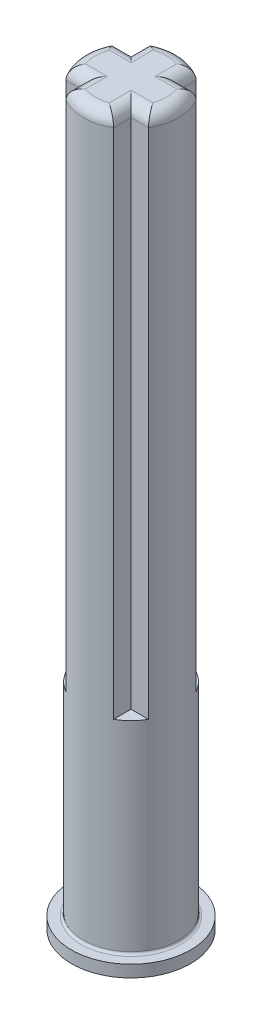
from build123d import *

# Parameters (mm, degrees)
SKETCH1_W           = 2
SKETCH1_H           = 0.732050808
SKETCH1_W_2         = 0.732050808
SKETCH1_H_2         = 2
BOSS_EXTRUDE1_DEPTH = 22
SKETCH2_R           = 2
BOSS_EXTRUDE2_DEPTH = 9
SKETCH3_R           = 2.5
BOSS_EXTRUDE3_DEPTH = 0.5
FILLET1_R           = 0.5
FILLET2_R           = 0.1


with BuildPart() as part:
    # Sketch1 → Boss-Extrude1 (new body)
    with BuildSketch(Plane(origin=(0, 0, 0), x_dir=(1, 0, 0), z_dir=(0, 1, 0))):
        with BuildLine():
            Line((-1, 1.732050808), (1, 1.732050808))
            ThreePointArc((1, 1.732050808), (0, 2), (-1, 1.732050808))
        make_face()
        with Locations((0, 1.366025404)):
            Rectangle(SKETCH1_W, SKETCH1_H)
        with BuildLine():
            Line((1.732050808, -1), (1.732050808, 1))
            ThreePointArc((1.732050808, 1), (2, 0), (1.732050808, -1))
        make_face()
        with Locations((1.366025404, 0)):
            Rectangle(SKETCH1_W_2, SKETCH1_H_2)
        Rectangle(SKETCH1_W, SKETCH1_H_2)
        with Locations((-1.366025404, 0)):
            Rectangle(SKETCH1_W_2, SKETCH1_H_2)
        with BuildLine():
            Line((-1.732050808, -1), (-1.732050808, 1))
            ThreePointArc((-1.732050808, 1), (-2, 0), (-1.732050808, -1))
        make_face()
        with Locations((0, -1.366025404)):
            Rectangle(SKETCH1_W, SKETCH1_H)
        with BuildLine():
            Line((-1, -1.732050808), (1, -1.732050808))
            ThreePointArc((1, -1.732050808), (0, -2), (-1, -1.732050808))
        make_face()
    extrude(amount=BOSS_EXTRUDE1_DEPTH)

    # Sketch2 → Boss-Extrude2 (add)
    with BuildSketch(Plane.XZ):
        with Locations(Location((0, 0, 0), (0, 0, 270))):
            Circle(SKETCH2_R)
    extrude(amount=BOSS_EXTRUDE2_DEPTH)

    # Sketch3 → Boss-Extrude3 (add)
    with BuildSketch(Plane.XZ.offset(9)):
        with Locations(Location((0, 0, 0), (0, 0, 270))):
            Circle(SKETCH3_R)
    extrude(amount=-BOSS_EXTRUDE3_DEPTH)

    # Fillet1
    fillet1_edges = [part.edges().sort_by_distance(p)[0] for p in [
        (-1, 22, -1.366025404),
        (-1.366025404, 22, -1),
        (-2, 22, 0),
        (-1.366025404, 22, 1),
        (-1, 22, 1.366025404),
        (0, 22, 2),
        (1, 22, 1.366025404),
        (1.366025404, 22, 1),
        (0, 22, -2),
        (2, 22, 0),
        (1.366025404, 22, -1),
        (1, 22, -1.366025404),
    ]]
    fillet(fillet1_edges, radius=FILLET1_R)

    # Fillet2
    fillet2_edges = [part.edges().sort_by_distance(p)[0] for p in [
        (0, -8.5, 2),
    ]]
    fillet(fillet2_edges, radius=FILLET2_R)


solid = part.part
